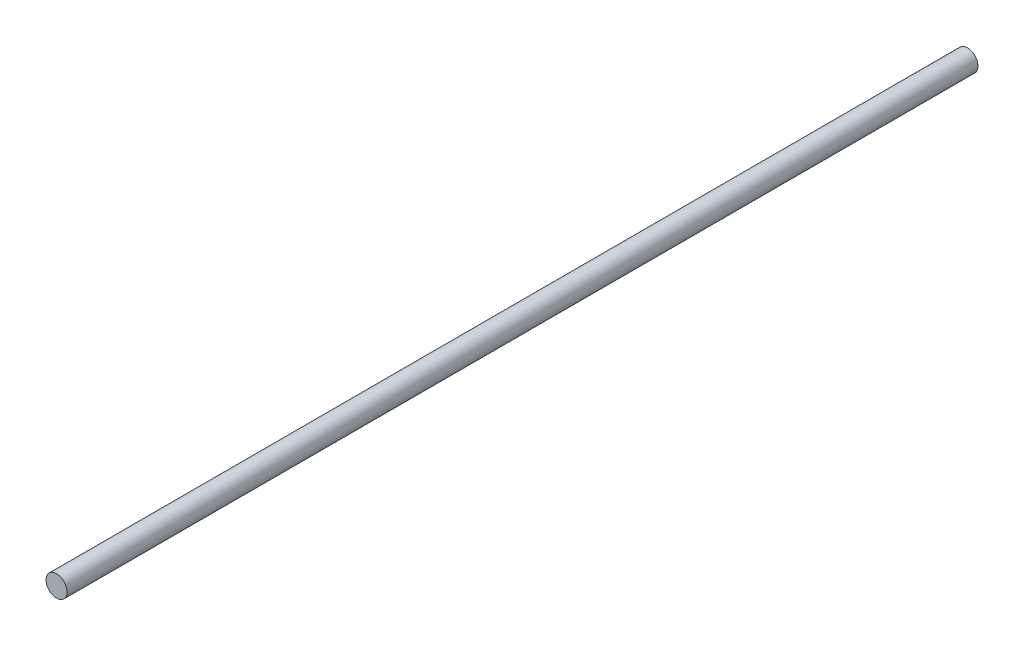
from build123d import *

# Parameters (mm, degrees)
SKETCH_1_R      = 2.9
EXTRUDE_1_DEPTH = 250


with BuildPart() as part:
    # 草图1 → 凸台-拉伸1 (new body)
    with BuildSketch(Plane.XY):
        Circle(SKETCH_1_R)
    extrude(amount=EXTRUDE_1_DEPTH)


solid = part.part
